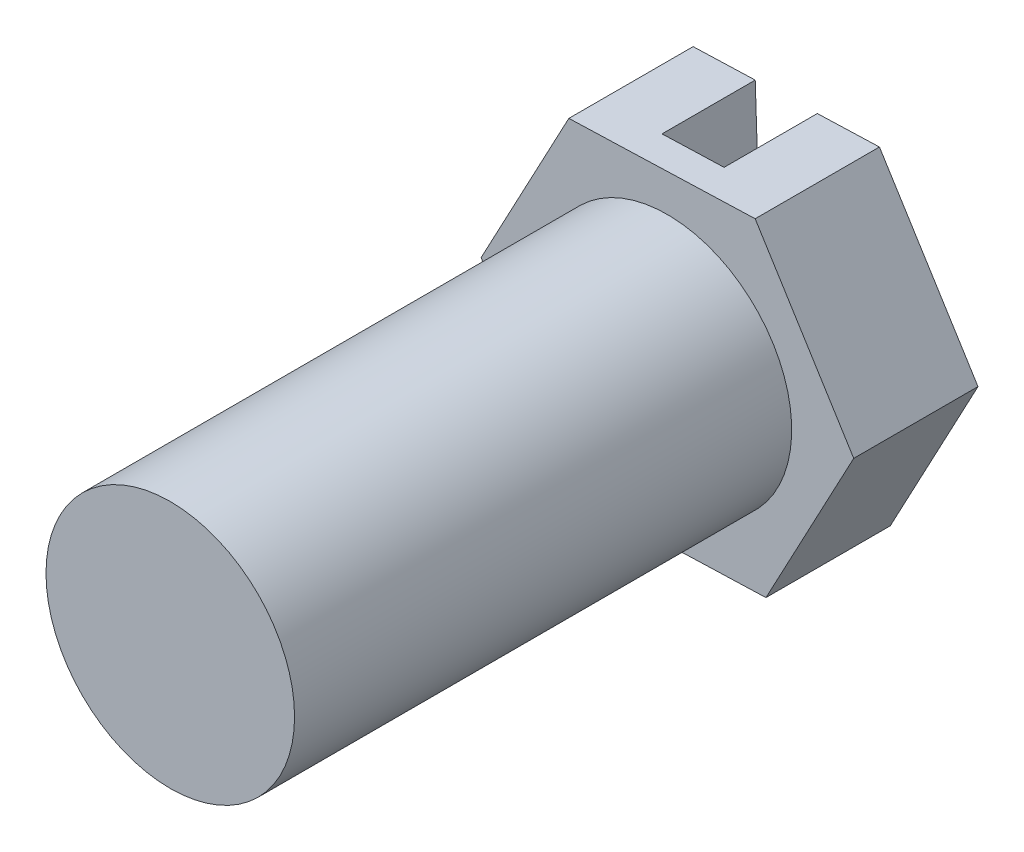
from build123d import *

# Parameters (mm, degrees)
SKETCH_1_R          = 0.2
EXTRUDE_1_DEPTH     = 0.8
SKETCH_2_R          = 0.3
EXTRUDE_2_DEPTH     = 0.2
SKETCH_3_R          = 0.340289424
CUT_EXTRUDE_1_DEPTH = 0.2
CUT_EXTRUDE_2_DEPTH = 0.15


with BuildPart() as part:
    # 草图1 → 凸台-拉伸1 (new body)
    with BuildSketch(Plane.XY):
        Circle(SKETCH_1_R)
    extrude(amount=EXTRUDE_1_DEPTH)

    # 草图2 → 凸台-拉伸2 (add)
    with BuildSketch(Plane(origin=(0, 0, 0), x_dir=(-1, 0, 0), z_dir=(0, 0, -1))):
        Circle(SKETCH_2_R)
    extrude(amount=EXTRUDE_2_DEPTH)

    # 草图3 → 切除-拉伸1 (cut)
    with BuildSketch(Plane(origin=(0, 0, -0.2), x_dir=(-1, 0, 0), z_dir=(0, 0, -1))):
        Circle(SKETCH_3_R)
        Polygon((0.141221925, -0.264681635), (0.299831982, -0.010039042), (0.158610057, 0.254642592), (-0.141221925, 0.264681635), (-0.299831982, 0.010039042), (-0.158610057, -0.254642592), align=None, mode=Mode.SUBTRACT)
    extrude(amount=-CUT_EXTRUDE_1_DEPTH, mode=Mode.SUBTRACT)

    # 草图4 → 切除-拉伸2 (cut)
    with BuildSketch(Plane(origin=(0, 0, -0.2), x_dir=(-1, 0, 0), z_dir=(0, 0, -1))):
        Polygon((0.041277931, -0.261335287), (0.058666063, 0.25798894), (-0.041277931, 0.261335287), (-0.058666063, -0.25798894), align=None)
    extrude(amount=-CUT_EXTRUDE_2_DEPTH, mode=Mode.SUBTRACT)


solid = part.part
